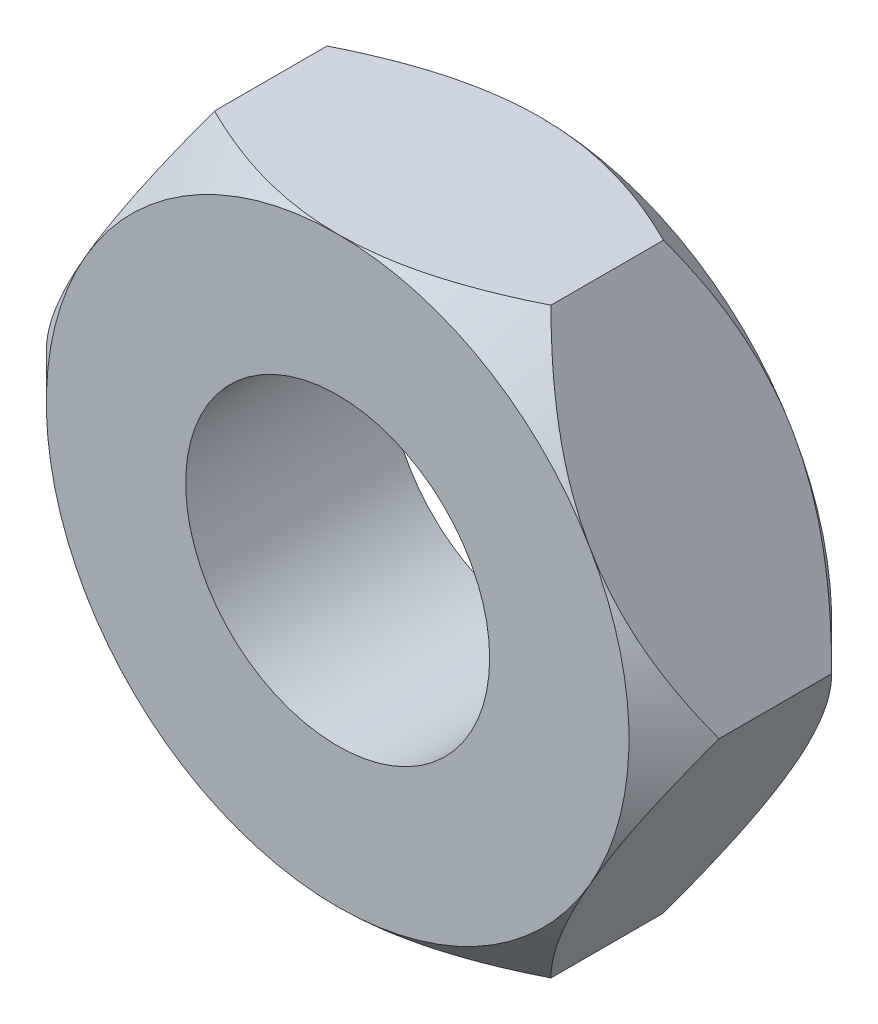
from build123d import *

# Parameters (mm, degrees)
BOSS_EXTRUDE1_DEPTH = 6
SKETCH2_OUTSIDE_W   = 39.322
SKETCH2_OUTSIDE_H   = 36.654
SKETCH2_OUTSIDE_R   = 8.625
CUT_EXTRUDE1_DEPTH  = 6
CUT_EXTRUDE1_DRAFT  = -45
SKETCH3_OUTSIDE_W   = 39.322
SKETCH3_OUTSIDE_H   = 36.654
SKETCH3_OUTSIDE_R   = 8.625
CUT_EXTRUDE2_DEPTH  = 6
CUT_EXTRUDE2_DRAFT  = -45
SKETCH4_R           = 4.5
CUT_EXTRUDE3_DEPTH  = 7


with BuildPart() as part:
    # Sketch1 → Boss-Extrude1 (new body)
    with BuildSketch(Plane.XY):
        Polygon((9.959292144, 0), (4.979646072, 8.625), (-4.979646072, 8.625), (-9.959292144, 0), (-4.979646072, -8.625), (4.979646072, -8.625), align=None)
    extrude(amount=BOSS_EXTRUDE1_DEPTH)


with BuildPart() as cut_extrude1_tool:
    # Sketch2 outside → Cut-Extrude1 (with draft: the straight prism first)
    with BuildSketch(Plane.XY.offset(6)):
        Rectangle(SKETCH2_OUTSIDE_W, SKETCH2_OUTSIDE_H)
        Circle(SKETCH2_OUTSIDE_R, mode=Mode.SUBTRACT)
    extrude(amount=-CUT_EXTRUDE1_DEPTH)
    # Cut-Extrude1: the draft: its side faces are tilted about the plane it starts from
    cut_extrude1_sides = [cut_extrude1_tool.faces().sort_by_distance(p)[0] for p in [
        (0, -18.327, 3),
        (19.661, 0, 3),
        (0, 18.327, 3),
        (-19.661, 0, 3),
        (-8.625, 0, 3),
    ]]
    draft(cut_extrude1_sides, Plane.XY.offset(6), CUT_EXTRUDE1_DRAFT)


with BuildPart() as part_1:
    add(part.part)

    # Cut-Extrude1: cut by cut_extrude1_tool
    add(cut_extrude1_tool.part, mode=Mode.SUBTRACT)


with BuildPart() as cut_extrude2_tool:
    # Sketch3 outside → Cut-Extrude2 (with draft: the straight prism first)
    with BuildSketch(Plane(origin=(0, 0, 0), x_dir=(-1, 0, 0), z_dir=(0, 0, -1))):
        Rectangle(SKETCH3_OUTSIDE_W, SKETCH3_OUTSIDE_H)
        Circle(SKETCH3_OUTSIDE_R, mode=Mode.SUBTRACT)
    extrude(amount=-CUT_EXTRUDE2_DEPTH)
    # Cut-Extrude2: the draft: its side faces are tilted about the plane it starts from
    cut_extrude2_sides = [cut_extrude2_tool.faces().sort_by_distance(p)[0] for p in [
        (0, -18.327, 3),
        (-19.661, 0, 3),
        (0, 18.327, 3),
        (19.661, 0, 3),
        (8.625, 0, 3),
    ]]
    draft(cut_extrude2_sides, Plane(origin=(0, 0, 0), x_dir=(-1, 0, 0), z_dir=(0, 0, -1)), CUT_EXTRUDE2_DRAFT)


with BuildPart() as part_2:
    add(part_1.part)

    # Cut-Extrude2: cut by cut_extrude2_tool
    add(cut_extrude2_tool.part, mode=Mode.SUBTRACT)

    # Sketch4 → Cut-Extrude3 (cut, through all)
    with BuildSketch(Plane.XY.offset(6)):
        Circle(SKETCH4_R)
    extrude(amount=-CUT_EXTRUDE3_DEPTH, mode=Mode.SUBTRACT)


solid = part_2.part
